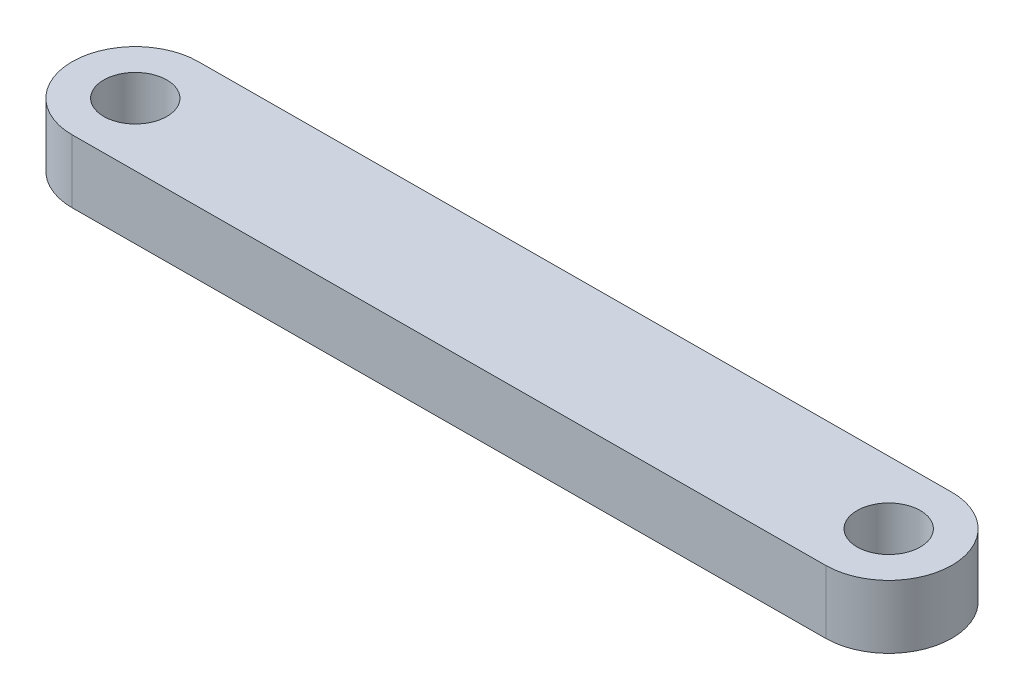
from build123d import *

# Parameters (mm, degrees)
SKETCH1_R           = 1.5
BOSS_EXTRUDE1_DEPTH = 3


with BuildPart() as part:
    # Sketch1 → Boss-Extrude1 (new body)
    with BuildSketch(Plane(origin=(0, 0, 0), x_dir=(1, 0, 0), z_dir=(0, 1, 0))):
        with BuildLine():
            Line((3.344532209, 3.466749545), (-32.184472752, 3.283207502))
            ThreePointArc((-32.184472752, 3.283207502), (-35.184472752, 0.283207502), (-32.184472752, -2.716792498))
            Line((-32.184472752, -2.716792498), (-32.153477714, -2.716632379))
            Line((-32.153477714, -2.716632379), (3.375527237, -2.533090335))
            Line((3.375527237, -2.533090335), (3.406522296, -2.532930216))
            ThreePointArc((3.406522296, -2.532930216), (6.375487217, 0.482407396), (3.375527248, 3.466909665))
            Line((3.375527248, 3.466909665), (3.344532209, 3.466749545))
        make_face()
        with Locations((-32.184472752, 0.283207502)):
            Circle(SKETCH1_R, mode=Mode.SUBTRACT)
        with Locations((3.375527248, 0.466909665)):
            Circle(SKETCH1_R, mode=Mode.SUBTRACT)
    extrude(amount=BOSS_EXTRUDE1_DEPTH)


solid = part.part
